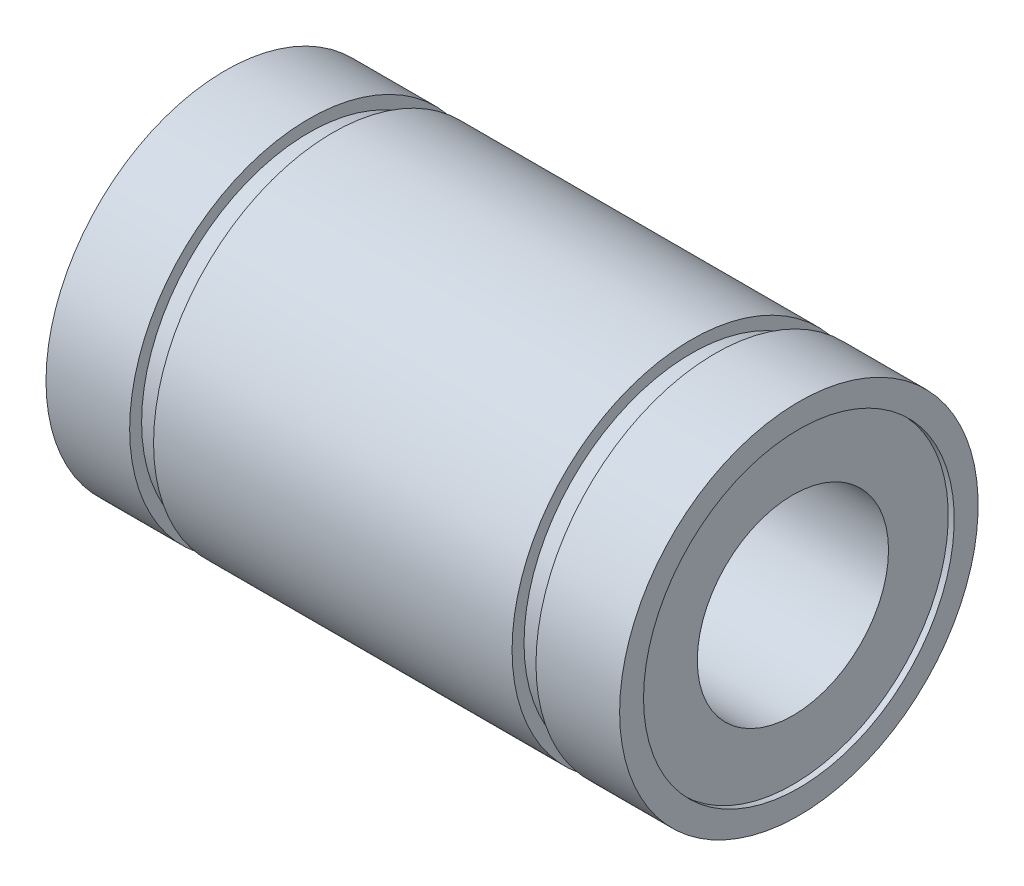
from build123d import *


with BuildPart() as part:
    # Sketch1 → Revolve1 (revolve)
    with BuildSketch(Plane(origin=(0, 0, 0), x_dir=(1, 0, 0), z_dir=(0, 1, 0))):
        Polygon((-11.75, 4), (11.75, 4), (11.75, 6.5), (12, 6.5), (12, 7.5), (8.5, 7.5), (8.5, 7), (7.5, 7), (7.5, 7.5), (-7.5, 7.5), (-7.5, 7), (-8.5, 7), (-8.5, 7.5), (-12, 7.5), (-12, 6.5), (-11.75, 6.5), align=None)
    revolve(axis=Axis((-10.666666667, 0, 0), (1, 0, 0)))


solid = part.part
